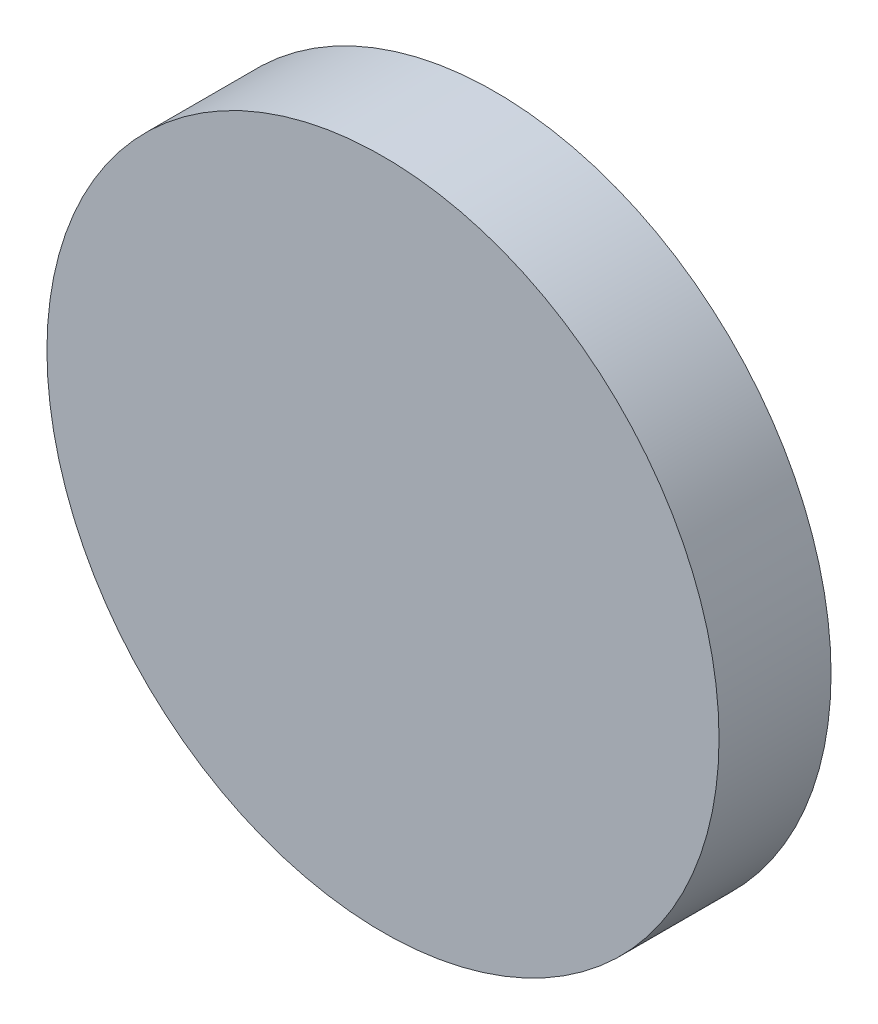
from build123d import *

# Parameters (mm, degrees)
SKETCH_1_R      = 15
EXTRUDE_1_DEPTH = 5


with BuildPart() as part:
    # 草图1 → 凸台-拉伸1 (new body)
    with BuildSketch(Plane.XY):
        Circle(SKETCH_1_R)
    extrude(amount=EXTRUDE_1_DEPTH)


solid = part.part
